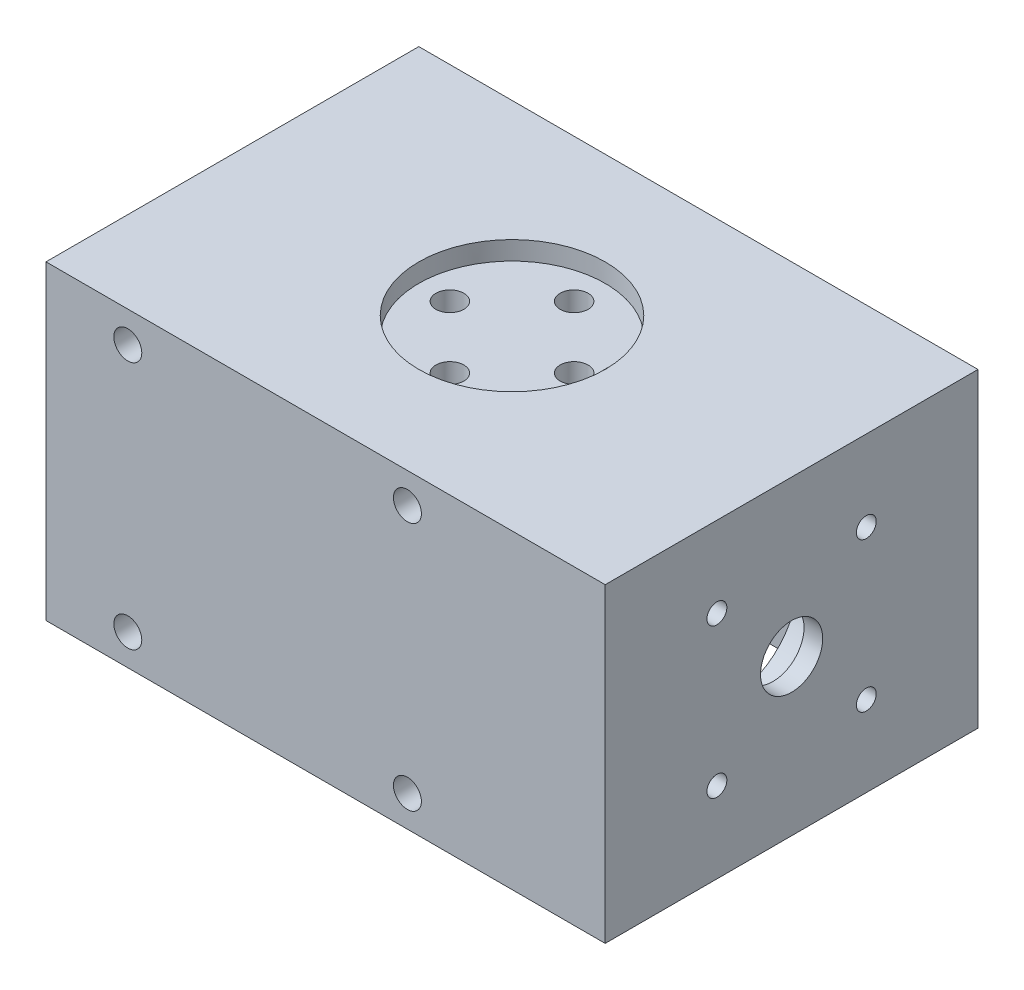
from build123d import *

# Parameters (mm, degrees)
SKETCH1_W           = 90
SKETCH1_H           = 60
BOSS_EXTRUDE1_DEPTH = 50
SKETCH2_W           = 70
SKETCH2_H           = 50
CUT_EXTRUDE1_DEPTH  = 40
CUT_EXTRUDE3_START  = 50
SKETCH1_5_R         = 2.25
CUT_EXTRUDE3_DEPTH  = 40
CUT_EXTRUDE4_START  = 50
SKETCH1_6_R         = 15
SKETCH1_6_R_2       = 2.25
CUT_EXTRUDE4_DEPTH  = 3
SKETCH3_R           = 5
CUT_EXTRUDE5_DEPTH  = 91
CUT_EXTRUDE7_START  = -10
SKETCH3_3_R         = 11
SKETCH3_3_R_2       = 5
SKETCH3_3_R_3       = 1.6
CUT_EXTRUDE7_DEPTH  = 7
CUT_EXTRUDE8_START  = -80
SKETCH3_4_R         = 11
SKETCH3_4_R_2       = 5
SKETCH3_4_R_3       = 1.6
CUT_EXTRUDE8_DEPTH  = 7
SKETCH3_5_R         = 1.6
CUT_EXTRUDE9_DEPTH  = 91
SKETCH4_R           = 2.25
CUT_EXTRUDE10_DEPTH = 60


with BuildPart() as part:
    # Sketch1 → Boss-Extrude1 (new body)
    with BuildSketch(Plane(origin=(0, 0, 0), x_dir=(1, 0, 0), z_dir=(0, 1, 0))):
        Rectangle(SKETCH1_W, SKETCH1_H)
    extrude(amount=BOSS_EXTRUDE1_DEPTH)

    # Sketch2 → Cut-Extrude1 (cut)
    with BuildSketch(Plane.XZ):
        Rectangle(SKETCH2_W, SKETCH2_H)
    extrude(amount=-CUT_EXTRUDE1_DEPTH, mode=Mode.SUBTRACT)

    # Sketch1_5 → Cut-Extrude3 (cut)
    with BuildSketch(Plane(origin=(0, 0, 0), x_dir=(1, 0, 0), z_dir=(0, 1, 0)).offset(CUT_EXTRUDE3_START)):
        with Locations((0, -10)):
            Circle(SKETCH1_5_R)
        with Locations((-10, 0)):
            Circle(SKETCH1_5_R)
        with Locations((0, 10)):
            Circle(SKETCH1_5_R)
        with Locations((10, 0)):
            Circle(SKETCH1_5_R)
    extrude(amount=-CUT_EXTRUDE3_DEPTH, mode=Mode.SUBTRACT)

    # Sketch1_6 → Cut-Extrude4 (cut)
    with BuildSketch(Plane(origin=(0, 0, 0), x_dir=(1, 0, 0), z_dir=(0, 1, 0)).offset(CUT_EXTRUDE4_START)):
        Circle(SKETCH1_6_R)
        with Locations((-10, 0)):
            Circle(SKETCH1_6_R_2, mode=Mode.SUBTRACT)
        with Locations((0, -10)):
            Circle(SKETCH1_6_R_2, mode=Mode.SUBTRACT)
        with Locations((10, 0)):
            Circle(SKETCH1_6_R_2, mode=Mode.SUBTRACT)
        with Locations((0, 10)):
            Circle(SKETCH1_6_R_2, mode=Mode.SUBTRACT)
    extrude(amount=-CUT_EXTRUDE4_DEPTH, mode=Mode.SUBTRACT)

    # Sketch3 → Cut-Extrude5 (cut, through all)
    with BuildSketch(Plane.ZY.offset(45)):
        with Locations((0, 25)):
            Circle(SKETCH3_R)
    extrude(amount=-CUT_EXTRUDE5_DEPTH, mode=Mode.SUBTRACT)

    # Sketch3_3 → Cut-Extrude7 (cut)
    with BuildSketch(Plane.ZY.offset(45).offset(CUT_EXTRUDE7_START)):
        with Locations((0, 25)):
            Circle(SKETCH3_3_R)
        with Locations((0, 25)):
            Circle(SKETCH3_3_R_2, mode=Mode.SUBTRACT)
        with Locations((-12.02081528, 37.02081528)):
            Circle(SKETCH3_3_R_3)
        with Locations((12.02081528, 37.02081528)):
            Circle(SKETCH3_3_R_3)
        with Locations((12.02081528, 12.97918472)):
            Circle(SKETCH3_3_R_3)
        with Locations((-12.02081528, 12.97918472)):
            Circle(SKETCH3_3_R_3)
    extrude(amount=CUT_EXTRUDE7_DEPTH, mode=Mode.SUBTRACT)

    # Sketch3_4 → Cut-Extrude8 (cut)
    with BuildSketch(Plane.ZY.offset(45).offset(CUT_EXTRUDE8_START)):
        with Locations((0, 25)):
            Circle(SKETCH3_4_R)
        with Locations((0, 25)):
            Circle(SKETCH3_4_R_2, mode=Mode.SUBTRACT)
        with Locations((-12.02081528, 37.02081528)):
            Circle(SKETCH3_4_R_3)
        with Locations((12.02081528, 37.02081528)):
            Circle(SKETCH3_4_R_3)
        with Locations((12.02081528, 12.97918472)):
            Circle(SKETCH3_4_R_3)
        with Locations((-12.02081528, 12.97918472)):
            Circle(SKETCH3_4_R_3)
    extrude(amount=-CUT_EXTRUDE8_DEPTH, mode=Mode.SUBTRACT)

    # Sketch3_5 → Cut-Extrude9 (cut, through all)
    with BuildSketch(Plane.ZY.offset(45)):
        with Locations((-12.02081528, 37.02081528)):
            Circle(SKETCH3_5_R)
        with Locations((12.02081528, 37.02081528)):
            Circle(SKETCH3_5_R)
        with Locations((12.02081528, 12.97918472)):
            Circle(SKETCH3_5_R)
        with Locations((-12.02081528, 12.97918472)):
            Circle(SKETCH3_5_R)
    extrude(amount=-CUT_EXTRUDE9_DEPTH, mode=Mode.SUBTRACT)

    # Sketch4 → Cut-Extrude10 (cut)
    with BuildSketch(Plane.XY.offset(30)):
        with Locations((-31.833799112, 5)):
            Circle(SKETCH4_R)
        with Locations((-31.833799112, 45.010389169)):
            Circle(SKETCH4_R)
        with Locations((13.166200888, 5)):
            Circle(SKETCH4_R)
        with Locations((13.166200888, 45.10389169)):
            Circle(SKETCH4_R)
    extrude(amount=-CUT_EXTRUDE10_DEPTH, mode=Mode.SUBTRACT)


solid = part.part
